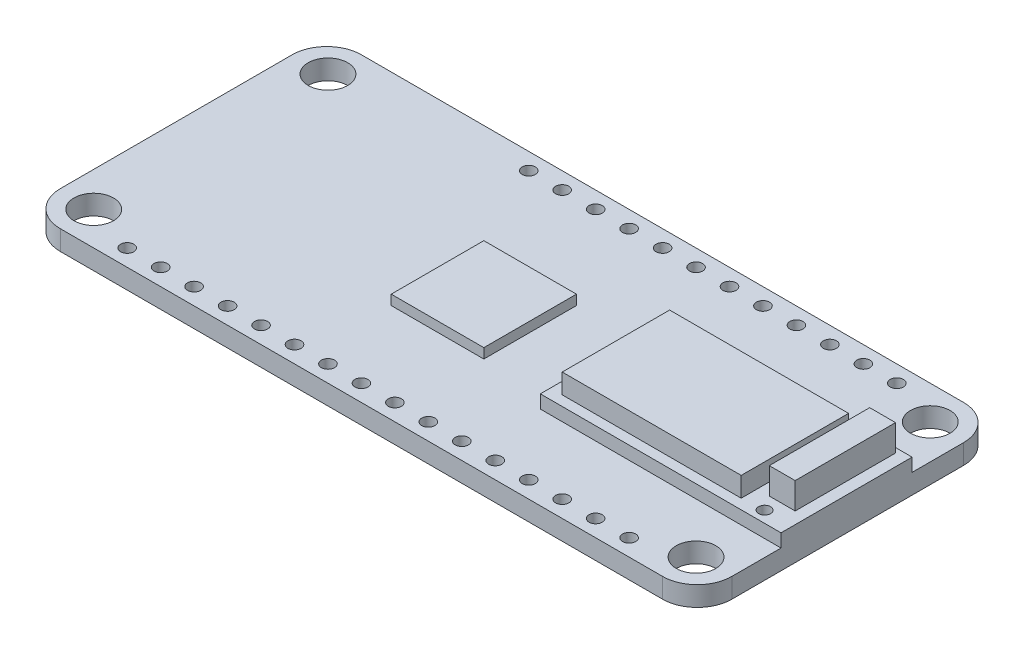
from build123d import *

# Parameters (mm, degrees)
SKETCH1_R           = 0.5
SKETCH1_R_2         = 1.5
BOSS_EXTRUDE1_DEPTH = 1.5
SKETCH3_W           = 13.585431646
SKETCH3_H           = 8.151258988
BOSS_EXTRUDE2_DEPTH = 2.5
SKETCH4_W           = 1.964423464
SKETCH4_H           = 7.620608266
BOSS_EXTRUDE3_DEPTH = 3
SKETCH5_W           = 18.269857108
SKETCH5_H           = 9.951352814
SKETCH5_R           = 0.457577412
BOSS_EXTRUDE4_DEPTH = 1
SKETCH6_W           = 7.030512295
SKETCH6_H           = 7.030512295
BOSS_EXTRUDE5_DEPTH = 0.75


with BuildPart() as part:
    # Sketch1 → Boss-Extrude1 (new body)
    with BuildSketch(Plane(origin=(0, 0, 0), x_dir=(1, 0, 0), z_dir=(0, 1, 0))):
        with BuildLine():
            Line((2.63, 0), (48.35, 0))
            ThreePointArc((48.35, 0), (50.209690835, -0.770309165), (50.98, -2.63))
            Line((50.98, -2.63), (50.98, -20.23))
            ThreePointArc((50.98, -20.23), (50.209690835, -22.089690835), (48.35, -22.86))
            Line((48.35, -22.86), (2.63, -22.86))
            ThreePointArc((2.63, -22.86), (0.770309165, -22.089690835), (0, -20.23))
            Line((0, -20.23), (0, -2.63))
            ThreePointArc((0, -2.63), (0.770309165, -0.770309165), (2.63, 0))
        make_face()
        with Locations((6.44, -21.59)):
            Circle(SKETCH1_R, mode=Mode.SUBTRACT)
        with Locations((8.98, -21.59)):
            Circle(SKETCH1_R, mode=Mode.SUBTRACT)
        with Locations((11.52, -21.59)):
            Circle(SKETCH1_R, mode=Mode.SUBTRACT)
        with Locations((14.06, -21.59)):
            Circle(SKETCH1_R, mode=Mode.SUBTRACT)
        with Locations((16.6, -21.59)):
            Circle(SKETCH1_R, mode=Mode.SUBTRACT)
        with Locations((19.14, -21.59)):
            Circle(SKETCH1_R, mode=Mode.SUBTRACT)
        with Locations((21.68, -21.59)):
            Circle(SKETCH1_R, mode=Mode.SUBTRACT)
        with Locations((24.22, -21.59)):
            Circle(SKETCH1_R, mode=Mode.SUBTRACT)
        with Locations((26.76, -21.59)):
            Circle(SKETCH1_R, mode=Mode.SUBTRACT)
        with Locations((29.3, -21.59)):
            Circle(SKETCH1_R, mode=Mode.SUBTRACT)
        with Locations((31.84, -21.59)):
            Circle(SKETCH1_R, mode=Mode.SUBTRACT)
        with Locations((34.38, -21.59)):
            Circle(SKETCH1_R, mode=Mode.SUBTRACT)
        with Locations((36.92, -21.59)):
            Circle(SKETCH1_R, mode=Mode.SUBTRACT)
        with Locations((39.46, -21.59)):
            Circle(SKETCH1_R, mode=Mode.SUBTRACT)
        with Locations((42, -21.59)):
            Circle(SKETCH1_R, mode=Mode.SUBTRACT)
        with Locations((44.54, -21.59)):
            Circle(SKETCH1_R, mode=Mode.SUBTRACT)
        with Locations((44.54, -1.27)):
            Circle(SKETCH1_R, mode=Mode.SUBTRACT)
        with Locations((42, -1.27)):
            Circle(SKETCH1_R, mode=Mode.SUBTRACT)
        with Locations((39.46, -1.27)):
            Circle(SKETCH1_R, mode=Mode.SUBTRACT)
        with Locations((36.92, -1.27)):
            Circle(SKETCH1_R, mode=Mode.SUBTRACT)
        with Locations((34.38, -1.27)):
            Circle(SKETCH1_R, mode=Mode.SUBTRACT)
        with Locations((31.84, -1.27)):
            Circle(SKETCH1_R, mode=Mode.SUBTRACT)
        with Locations((29.3, -1.27)):
            Circle(SKETCH1_R, mode=Mode.SUBTRACT)
        with Locations((26.76, -1.27)):
            Circle(SKETCH1_R, mode=Mode.SUBTRACT)
        with Locations((24.22, -1.27)):
            Circle(SKETCH1_R, mode=Mode.SUBTRACT)
        with Locations((21.68, -1.27)):
            Circle(SKETCH1_R, mode=Mode.SUBTRACT)
        with Locations((19.14, -1.27)):
            Circle(SKETCH1_R, mode=Mode.SUBTRACT)
        with Locations((16.6, -1.27)):
            Circle(SKETCH1_R, mode=Mode.SUBTRACT)
        with Locations((2.63, -2.54)):
            Circle(SKETCH1_R_2, mode=Mode.SUBTRACT)
        with Locations((2.63, -20.32)):
            Circle(SKETCH1_R_2, mode=Mode.SUBTRACT)
        with Locations((48.35, -20.32)):
            Circle(SKETCH1_R_2, mode=Mode.SUBTRACT)
        with Locations((48.35, -2.54)):
            Circle(SKETCH1_R_2, mode=Mode.SUBTRACT)
    extrude(amount=BOSS_EXTRUDE1_DEPTH)

    # Sketch3 → Boss-Extrude2 (add)
    with BuildSketch(Plane(origin=(0, 1.5, 0), x_dir=(1, 0, 0), z_dir=(0, 1, 0))):
        with Locations((40.399579876, -11.65885309)):
            Rectangle(SKETCH3_W, SKETCH3_H)
    extrude(amount=BOSS_EXTRUDE2_DEPTH)

    # Sketch4 → Boss-Extrude3 (add)
    with BuildSketch(Plane(origin=(0, 1.5, 0), x_dir=(1, 0, 0), z_dir=(0, 1, 0))):
        with Locations((49.100080702, -10.717871328)):
            Rectangle(SKETCH4_W, SKETCH4_H)
    extrude(amount=BOSS_EXTRUDE3_DEPTH)

    # Sketch5 → Boss-Extrude4 (add)
    with BuildSketch(Plane(origin=(0, 1.5, 0), x_dir=(1, 0, 0), z_dir=(0, 1, 0))):
        with Locations((41.845071446, -11.523458661)):
            Rectangle(SKETCH5_W, SKETCH5_H)
        with Locations((48.865489617, -15.632765099)):
            Circle(SKETCH5_R, mode=Mode.SUBTRACT)
    extrude(amount=BOSS_EXTRUDE4_DEPTH)

    # Sketch6 → Boss-Extrude5 (add)
    with BuildSketch(Plane(origin=(0, 1.5, 0), x_dir=(1, 0, 0), z_dir=(0, 1, 0))):
        with Locations((23.761662883, -11.839547187)):
            Rectangle(SKETCH6_W, SKETCH6_H)
    extrude(amount=BOSS_EXTRUDE5_DEPTH)


solid = part.part
